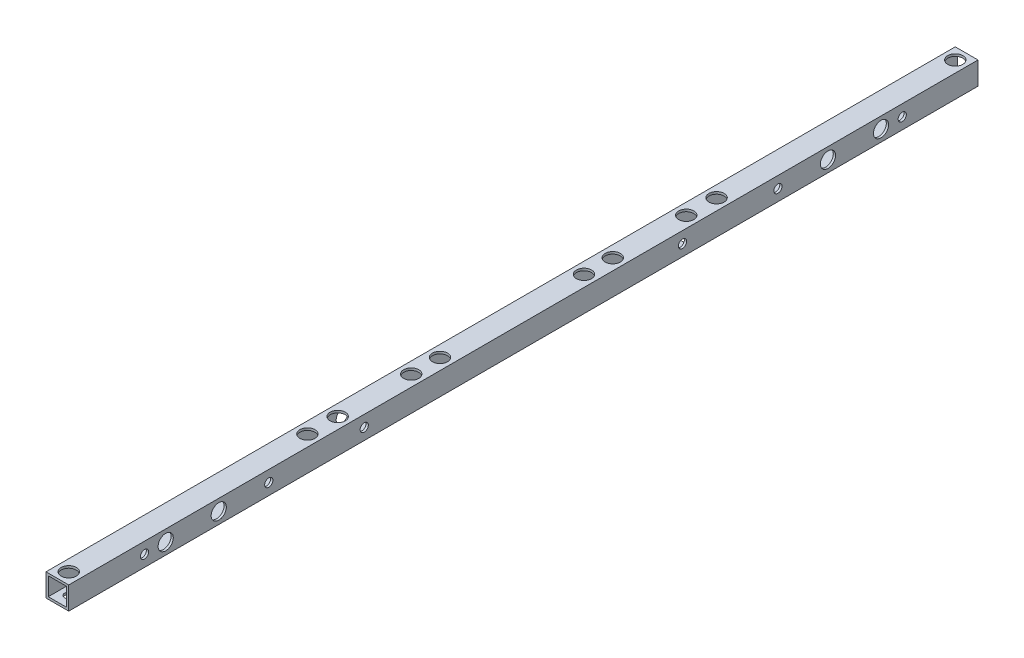
from build123d import *

# Parameters (mm, degrees)
SKETCH_1_W              = 15
SKETCH_1_H              = 15
SKETCH_1_W_2            = 12
SKETCH_1_H_2            = 12
EXTRUDE_1_DEPTH         = 600
SKETCH_3_R              = 2.7
CUT_EXTRUDE_2_DEPTH     = 25
SKETCH_4_R              = 2.7
CUT_EXTRUDE_3_DEPTH     = 20
SKETCH_6_R              = 2.75
CUT_EXTRUDE_5_DEPTH     = 30
SKETCH_7_R              = 5
CUT_EXTRUDE_6_DEPTH     = 10
SKETCH_8_R              = 5
CUT_EXTRUDE_7_DEPTH     = 10
SKETCH_9_R              = 5
CUT_EXTRUDE_8_DEPTH     = 10
HOLE_WIZARD_5_4_5_4_1_D = 5.4
CUT_EXTRUDE_9_REACH     = 17
SKETCH_15_R             = 5


with BuildPart() as part:
    # ｽｹｯﾁ1 → ﾎﾞｽ - 押し出し1 (new body)
    with BuildSketch(Plane.XY):
        Rectangle(SKETCH_1_W, SKETCH_1_H)
        Rectangle(SKETCH_1_W_2, SKETCH_1_H_2, mode=Mode.SUBTRACT)
    extrude(amount=EXTRUDE_1_DEPTH)

    # ｽｹｯﾁ3 → ｶｯﾄ - 押し出し2 (cut)
    with BuildSketch(Plane(origin=(0, 7.5, 0), x_dir=(1, 0, 0), z_dir=(0, 1, 0))):
        with Locations((0, -7.5)):
            Circle(SKETCH_3_R)
        with Locations((0, -592.5)):
            Circle(SKETCH_3_R)
        with Locations((0, -366.5)):
            Circle(SKETCH_3_R)
        with Locations((0, -233.5)):
            Circle(SKETCH_3_R)
    extrude(amount=-CUT_EXTRUDE_2_DEPTH, mode=Mode.SUBTRACT)

    # ｽｹｯﾁ4 → ｶｯﾄ - 押し出し3 (cut)
    with BuildSketch(Plane(origin=(7.5, 0, 0), x_dir=(0, 0, -1), z_dir=(1, 0, 0))):
        with Locations((-536, 0)):
            Circle(SKETCH_4_R)
        with Locations((-501, 0)):
            Circle(SKETCH_4_R)
        with Locations((-99, 0)):
            Circle(SKETCH_4_R)
        with Locations((-64, 0)):
            Circle(SKETCH_4_R)
        with Locations((-132, 0)):
            Circle(SKETCH_4_R)
        with Locations((-195, 0)):
            Circle(SKETCH_4_R)
        with Locations((-50, 0)):
            Circle(SKETCH_4_R)
        with Locations((-550, 0)):
            Circle(SKETCH_4_R)
        with Locations((-405, 0)):
            Circle(SKETCH_4_R)
        with Locations((-468, 0)):
            Circle(SKETCH_4_R)
    extrude(amount=-CUT_EXTRUDE_3_DEPTH, mode=Mode.SUBTRACT)

    # ｽｹｯﾁ6 → ｶｯﾄ - 押し出し5 (cut)
    with BuildSketch(Plane(origin=(0, 7.5, 0), x_dir=(1, 0, 0), z_dir=(0, 1, 0))):
        with Locations((0, -435)):
            Circle(SKETCH_6_R)
        with Locations((0, -415)):
            Circle(SKETCH_6_R)
        with Locations((0, -165)):
            Circle(SKETCH_6_R)
        with Locations((0, -185)):
            Circle(SKETCH_6_R)
    extrude(amount=-CUT_EXTRUDE_5_DEPTH, mode=Mode.SUBTRACT)

    # ｽｹｯﾁ7 → ｶｯﾄ - 押し出し6 (cut)
    with BuildSketch(Plane(origin=(0, 7.5, 0), x_dir=(1, 0, 0), z_dir=(0, 1, 0))):
        with Locations((0, -7.5)):
            Circle(SKETCH_7_R)
        with Locations((0, -165)):
            Circle(SKETCH_7_R)
        with Locations((0, -185)):
            Circle(SKETCH_7_R)
        with Locations((0, -233.5)):
            Circle(SKETCH_7_R)
        with Locations((0, -366.5)):
            Circle(SKETCH_7_R)
        with Locations((0, -415)):
            Circle(SKETCH_7_R)
        with Locations((0, -435)):
            Circle(SKETCH_7_R)
        with Locations((0, -592.5)):
            Circle(SKETCH_7_R)
    extrude(amount=-CUT_EXTRUDE_6_DEPTH, mode=Mode.SUBTRACT)

    # ｽｹｯﾁ8 → ｶｯﾄ - 押し出し7 (cut)
    with BuildSketch(Plane(origin=(7.5, 0, 0), x_dir=(0, 0, -1), z_dir=(1, 0, 0))):
        with Locations((-64, 0)):
            Circle(SKETCH_8_R)
        with Locations((-99, 0)):
            Circle(SKETCH_8_R)
        with Locations((-501, 0)):
            Circle(SKETCH_8_R)
        with Locations((-536, 0)):
            Circle(SKETCH_8_R)
    extrude(amount=-CUT_EXTRUDE_7_DEPTH, mode=Mode.SUBTRACT)

    # ｽｹｯﾁ9 → ｶｯﾄ - 押し出し8 (cut)
    with BuildSketch(Plane.ZY.offset(7.5)):
        with Locations((132, 0)):
            Circle(SKETCH_9_R)
        with Locations((50, 0)):
            Circle(SKETCH_9_R)
        with Locations((195, 0)):
            Circle(SKETCH_9_R)
        with Locations((405, 0)):
            Circle(SKETCH_9_R)
        with Locations((550, 0)):
            Circle(SKETCH_9_R)
        with Locations((468, 0)):
            Circle(SKETCH_9_R)
    extrude(amount=-CUT_EXTRUDE_8_DEPTH, mode=Mode.SUBTRACT)

    # Ø5.4 (5.4) 直径の穴1 (through all)
    with Locations(Plane(origin=(0, -7.5, 0), x_dir=(-1, 0, 0), z_dir=(0, -1, 0))):
        with Locations((0, -252.5), (0, -347.5)):
            Hole(HOLE_WIZARD_5_4_5_4_1_D / 2)

    # ｽｹｯﾁ15 → ｶｯﾄ - 押し出し9 (cut, up to next)
    with BuildSketch(Plane(origin=(0, 7.5, 0), x_dir=(1, 0, 0), z_dir=(0, 1, 0)), mode=Mode.PRIVATE) as cut_extrude_9_sk1:
        with Locations((0, -252.5)):
            Circle(SKETCH_15_R)
    cut_extrude_9_tool1 = extrude(cut_extrude_9_sk1.sketch, amount=-CUT_EXTRUDE_9_REACH, mode=Mode.PRIVATE) & part.part
    add(cut_extrude_9_tool1.solids().sort_by_distance((0, 7.5, 252.5))[0], mode=Mode.SUBTRACT)
    # ｽｹｯﾁ15 → ｶｯﾄ - 押し出し9 (cut, up to next)
    with BuildSketch(Plane(origin=(0, 7.5, 0), x_dir=(1, 0, 0), z_dir=(0, 1, 0)), mode=Mode.PRIVATE) as cut_extrude_9_sk2:
        with Locations((0, -347.5)):
            Circle(SKETCH_15_R)
    cut_extrude_9_tool2 = extrude(cut_extrude_9_sk2.sketch, amount=-CUT_EXTRUDE_9_REACH, mode=Mode.PRIVATE) & part.part
    add(cut_extrude_9_tool2.solids().sort_by_distance((0, 7.5, 347.5))[0], mode=Mode.SUBTRACT)


solid = part.part
